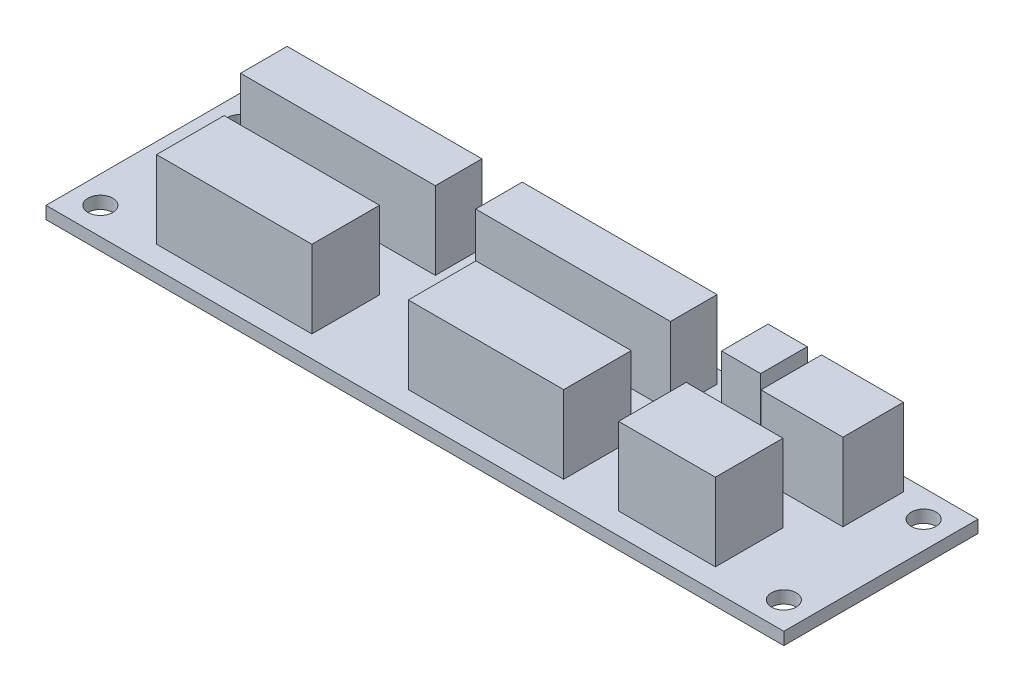
from build123d import *

# Parameters (mm, degrees)
SKETCH1_W           = 95
SKETCH1_H           = 25
SKETCH1_R           = 1.6
BOSS_EXTRUDE1_DEPTH = 1.6
SKETCH2_W           = 25.078547191
SKETCH2_H           = 6
SKETCH2_W_2         = 25.078547192
SKETCH2_W_3         = 5.04587156
SKETCH2_W_4         = 20
SKETCH2_H_2         = 8.7
SKETCH2_W_5         = 10.550458716
SKETCH2_H_3         = 7.798165138
SKETCH2_W_6         = 12.457684798
BOSS_EXTRUDE2_DEPTH = 10


with BuildPart() as part:
    # Sketch1 → Boss-Extrude1 (new body)
    with BuildSketch(Plane(origin=(0, 0, 0), x_dir=(1, 0, 0), z_dir=(0, 1, 0))):
        with Locations((18, -3)):
            Rectangle(SKETCH1_W, SKETCH1_H)
        with Locations((-26, 6)):
            Circle(SKETCH1_R, mode=Mode.SUBTRACT)
        with Locations((62, 6)):
            Circle(SKETCH1_R, mode=Mode.SUBTRACT)
        with Locations((62, -12)):
            Circle(SKETCH1_R, mode=Mode.SUBTRACT)
        with Locations((-26, -12)):
            Circle(SKETCH1_R, mode=Mode.SUBTRACT)
    extrude(amount=BOSS_EXTRUDE1_DEPTH)

    # Sketch2 → Boss-Extrude2 (add)
    with BuildSketch(Plane(origin=(0, 1.6, 0), x_dir=(1, 0, 0), z_dir=(0, 1, 0))):
        with Locations((-9.162561267, 4.749179336)):
            Rectangle(SKETCH2_W, SKETCH2_H)
        with Locations((21.112668091, 4.749179336)):
            Rectangle(SKETCH2_W_2, SKETCH2_H)
        with Locations((42.747706422, 4.749179336)):
            Rectangle(SKETCH2_W_3, SKETCH2_H)
        with Locations((-8.038302451, -8.374621296)):
            Rectangle(SKETCH2_W_4, SKETCH2_H_2)
        with Locations((52.380733945, 3.850096767)):
            Rectangle(SKETCH2_W_5, SKETCH2_H_3)
        with Locations((47.682340819, -8.374621296)):
            Rectangle(SKETCH2_W_6, SKETCH2_H_2)
        with Locations((24.37710187, -8.374621296)):
            Rectangle(SKETCH2_W_4, SKETCH2_H_2)
    extrude(amount=BOSS_EXTRUDE2_DEPTH)


solid = part.part
